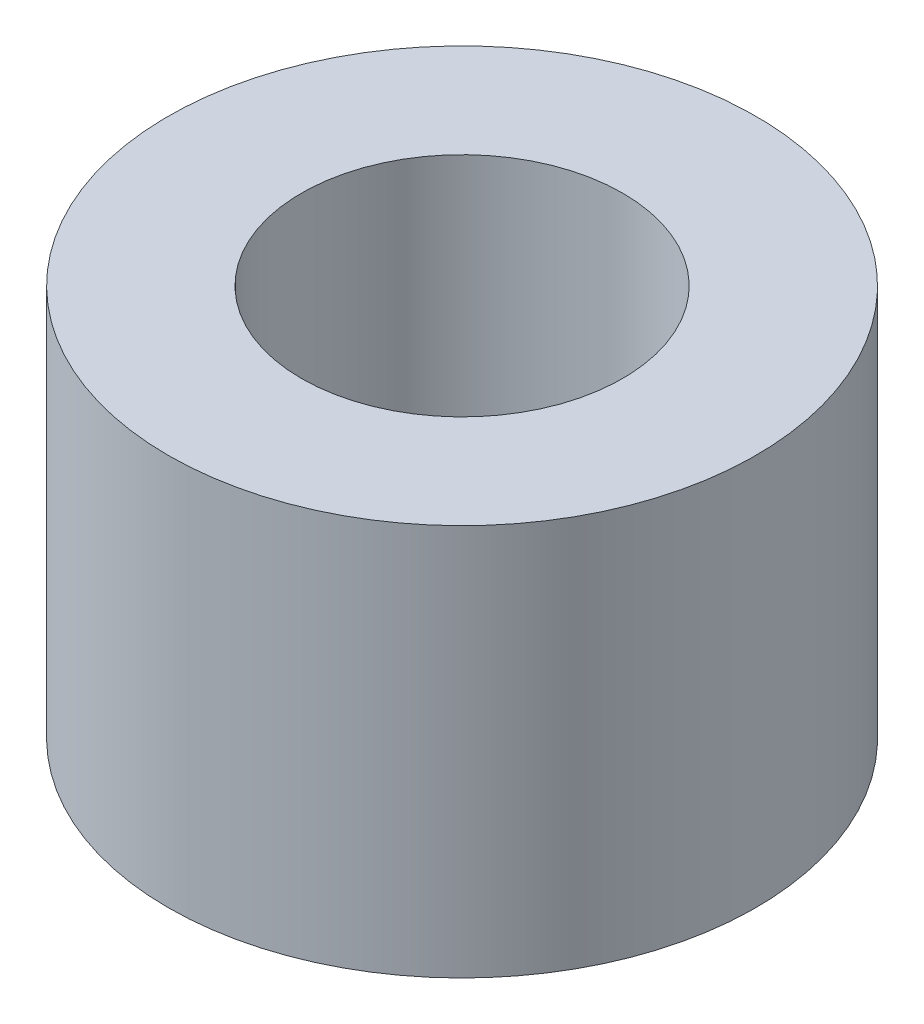
from build123d import *

# Parameters (mm, degrees)
SKETCH1_R           = 3.75
SKETCH1_R_2         = 2.05
BOSS_EXTRUDE1_DEPTH = 5


with BuildPart() as part:
    # Sketch1 → Boss-Extrude1 (new body)
    with BuildSketch(Plane(origin=(0, 0, 0), x_dir=(1, 0, 0), z_dir=(0, 1, 0))):
        Circle(SKETCH1_R)
        Circle(SKETCH1_R_2, mode=Mode.SUBTRACT)
    extrude(amount=BOSS_EXTRUDE1_DEPTH)


solid = part.part
